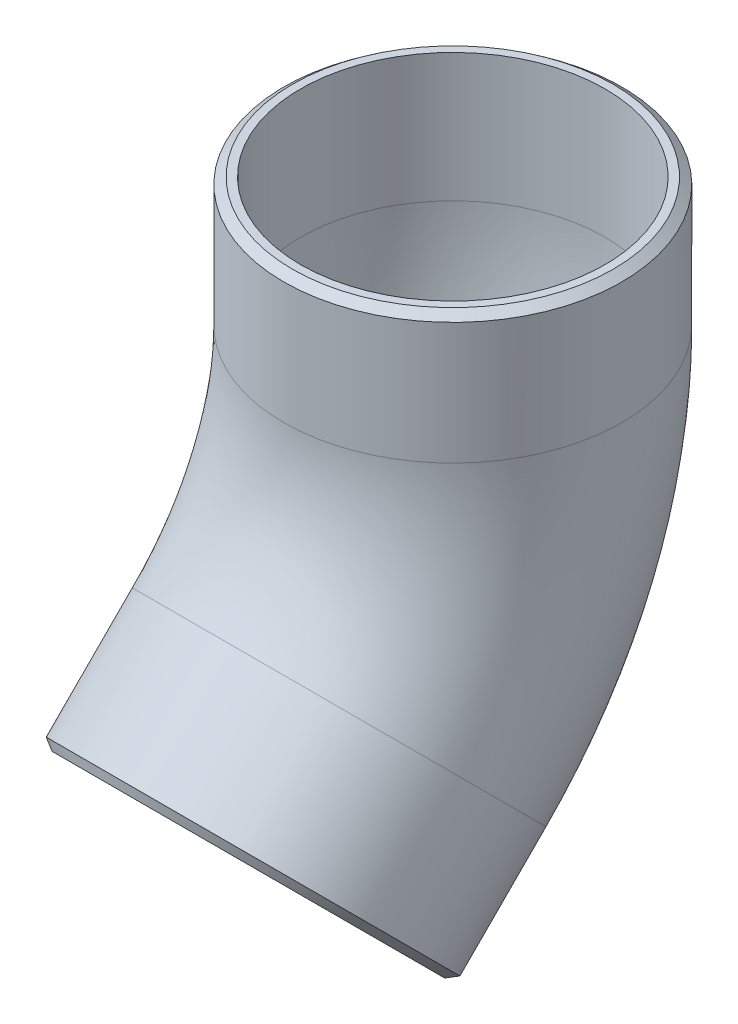
from build123d import *

# Parameters (mm, degrees)
SKETCH2_R    = 16.7005
SKETCH2_R_2  = 15.0495
SCALE1_SCALE = 0.095238095


with BuildPart() as part:
    # Sweep1: sweep along a path in Sketch1
    with BuildLine(Plane(origin=(0, 0, 0), x_dir=(0, 0, -1), z_dir=(1, 0, 0))) as sweep1_path:
        Line((-20.205576272, -20.205576272), (-11.225320151, -11.225320151))
        ThreePointArc((-11.225320151, -11.225320151), (-2.917365657, 1.208412421), (0, 15.875))
        Line((0, 15.875), (0, 28.575))
    # Sketch2 → Sweep1 (sweep)
    with BuildSketch(Plane(origin=(0, 28.575, 0), x_dir=(1, 0, 0), z_dir=(0, 1, 0))):
        Circle(SKETCH2_R)
        Circle(SKETCH2_R_2, mode=Mode.SUBTRACT)
    sweep(path=sweep1_path.line)

    # Sketch3 → Cut-Revolve1 (revolve, cut)
    with BuildSketch(Plane(origin=(0, 0, 0), x_dir=(0, 1, 0), z_dir=(-1, 0, 0))):
        Polygon((27.91720894, 16.7005), (28.575, 15.84325), (28.575, 16.7005), align=None)
    revolve(axis=Axis((0, 28.575, 0), (0, -1, 0)), mode=Mode.SUBTRACT)

    # Sketch3_7 → Cut-Revolve2 (revolve, cut)
    with BuildSketch(Plane(origin=(0, 0, 0), x_dir=(0, 1, 0), z_dir=(-1, 0, 0))):
        Polygon((-31.408445783, -9.002706761), (-32.014613072, -8.396539473), (-31.549484552, -7.931410954), align=None)
    revolve(axis=Axis((0, -11.225320151, 11.225320151), (0, -0.7071067811865535, 0.7071067811865417)), mode=Mode.SUBTRACT)


with BuildPart() as part_1:
    # Scale1: scaled about (0, 1.665203818, 4.020157643)
    add(part.part.scale(SCALE1_SCALE).moved(Location((0, 1.506612978, 3.637285487))))


solid = part_1.part
